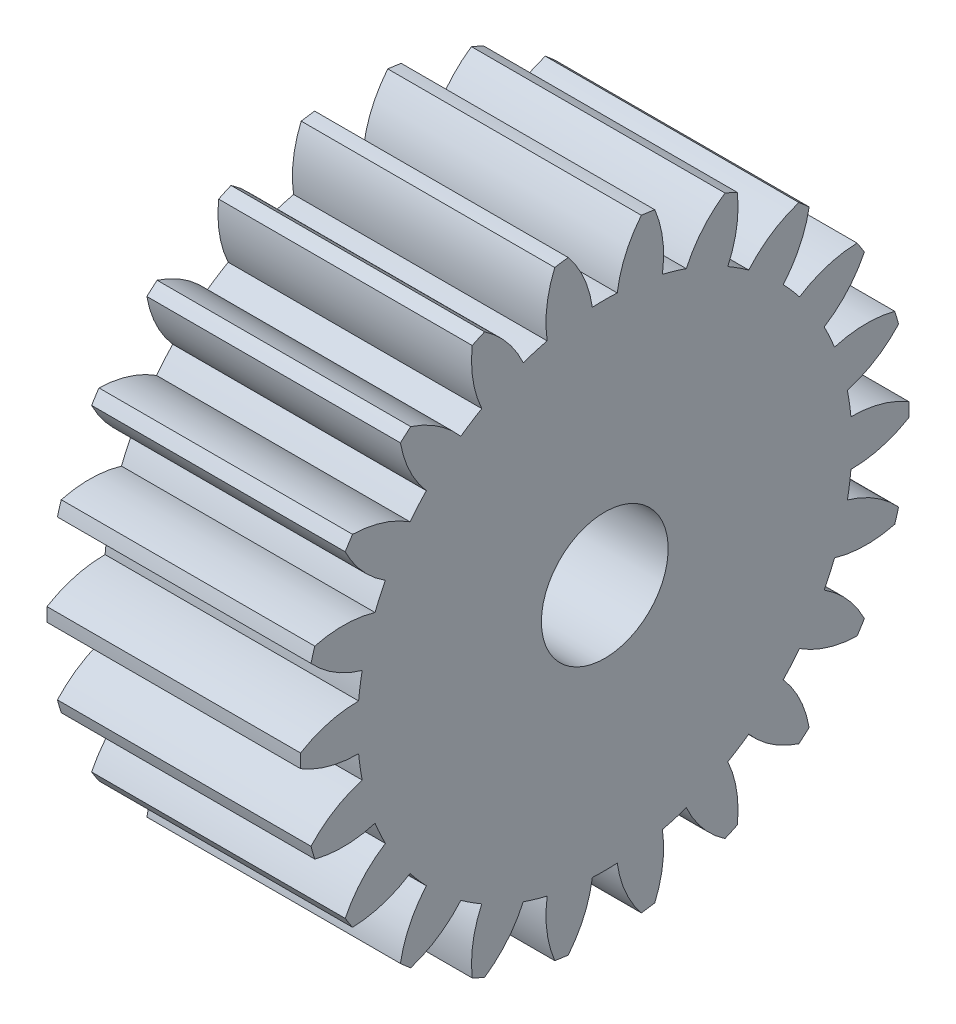
from build123d import *

# Parameters (mm, degrees)
BASPROSKE_W     = 10
BASPROSKE_H     = 12
TOOTHCUT_DEPTH  = 20.697715604
TEETHCUTS_COUNT = 22
TEETHCUTS_ANGLE = 343.636363636
BORSKE_R        = 2.5
BORE_DEPTH      = 50.0000508


with BuildPart() as part:
    # BasProSke → Base-Revolve (revolve)
    with BuildSketch(Plane(origin=(0, 0, 0), x_dir=(1, 0, 0), z_dir=(0, 1, 0)), mode=Mode.PRIVATE) as base_revolve_sk:
        with Locations((5, 6)):
            Rectangle(BASPROSKE_W, BASPROSKE_H)
    revolve(base_revolve_sk.sketch.rotate(Axis((-10, 0, 0), (1, 0, 0)), 180), axis=Axis((-10, 0, 0), (1, 0, 0)))

    # TooCutSke → ToothCut (cut, through all)
    with BuildSketch(Plane(origin=(0, 0, 0), x_dir=(0, 0, -1), z_dir=(1, 0, 0))):
        with BuildLine():
            ThreePointArc((0.491001901, 9.736627657), (0, 9.749), (-0.491001901, 9.736627657))
            ThreePointArc((-0.491001901, 9.736627657), (-0.822824844, 10.904005344), (-1.46093845, 11.936327074))
            ThreePointArc((-1.46093845, 11.936327074), (0, 12.0254), (1.46093845, 11.936327074))
            ThreePointArc((1.46093845, 11.936327074), (0.822824844, 10.904005344), (0.491001901, 9.736627657))
        make_face()
    toothcut = extrude(amount=TOOTHCUT_DEPTH, mode=Mode.SUBTRACT)

    # TeethCuts: ToothCut ×22 about axis
    teethcuts_axis = Axis((-10, 0, 0), (1, 0, 0))
    for i in range(1, TEETHCUTS_COUNT):
        add(toothcut.rotate(teethcuts_axis, i * TEETHCUTS_ANGLE / (TEETHCUTS_COUNT - 1)), mode=Mode.SUBTRACT)

    # BorSke → Bore (cut, symmetric)
    with BuildSketch(Plane(origin=(0, 0, 0), x_dir=(0, 0, -1), z_dir=(1, 0, 0))):
        with Locations(Location((0, 0, 0), (0, 0, 180))):
            Circle(BORSKE_R)
    extrude(amount=BORE_DEPTH, both=True, mode=Mode.SUBTRACT)


solid = part.part
